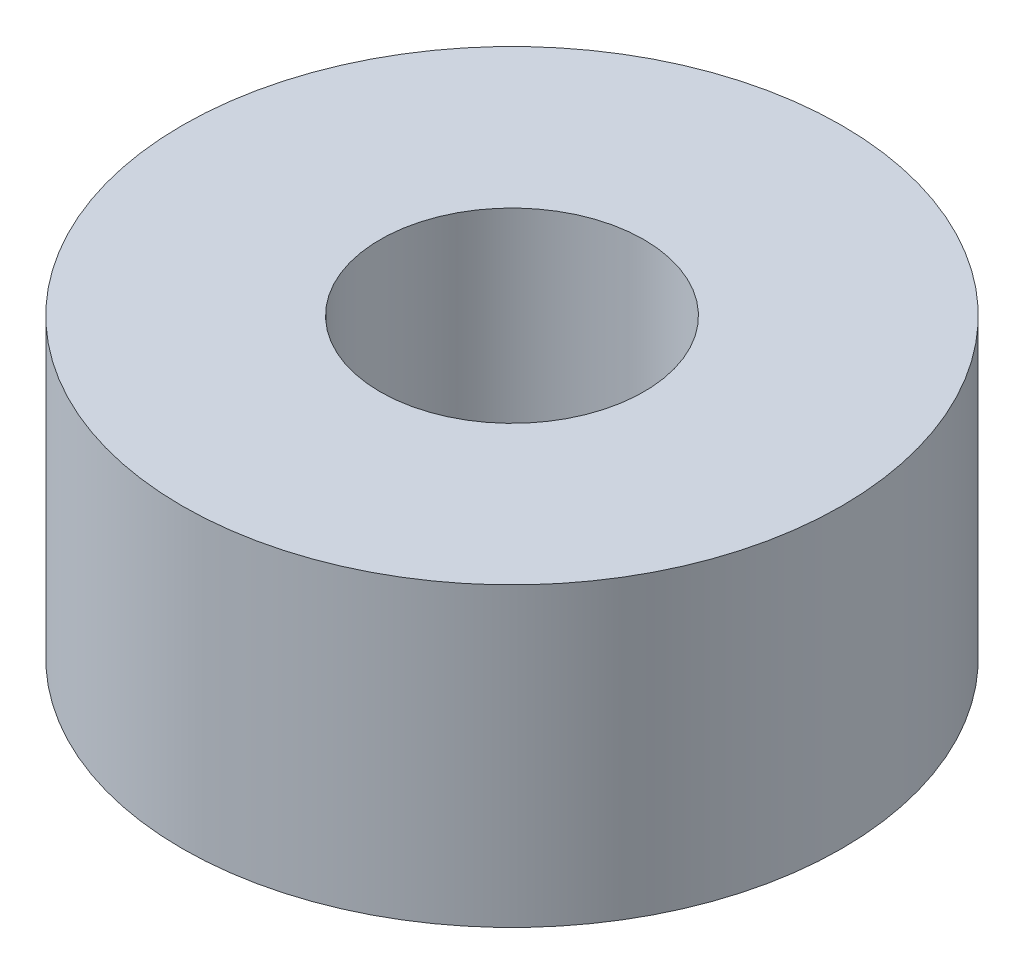
from build123d import *

# Parameters (mm, degrees)
SKETCH_1_R      = 5
SKETCH_1_R_2    = 2
EXTRUDE_1_DEPTH = 4.5


with BuildPart() as part:
    # 草图1 → 凸台-拉伸1 (new body)
    with BuildSketch(Plane(origin=(0, 0, 0), x_dir=(1, 0, 0), z_dir=(0, 1, 0))):
        Circle(SKETCH_1_R)
        Circle(SKETCH_1_R_2, mode=Mode.SUBTRACT)
    extrude(amount=EXTRUDE_1_DEPTH)


solid = part.part
